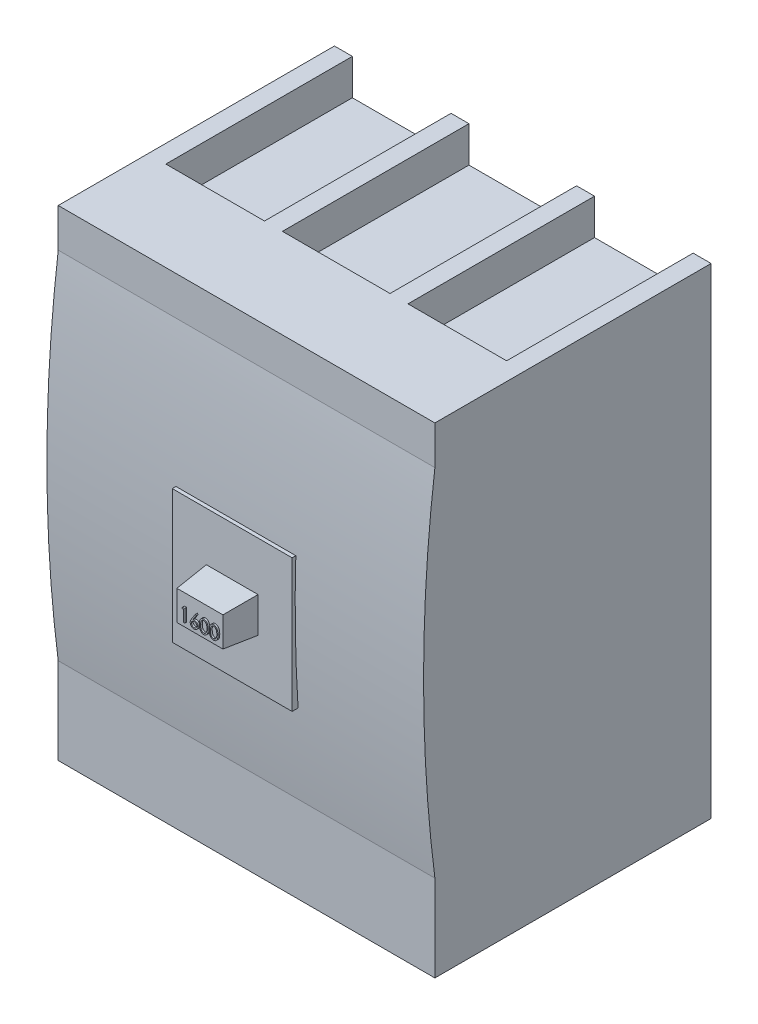
from build123d import *

# Parameters (mm, degrees)
CROQUIS1_W              = 210
CROQUIS1_H              = 268
SALIENTE_EXTRUIR1_DEPTH = 154
SALIENTE_EXTRUIR5_DEPTH = 210
CROQUIS9_W              = 66.83497729
CROQUIS9_H              = 74.198152754
SALIENTE_EXTRUIR6_DEPTH = 8
CROQUIS10_W             = 28.813391314
CROQUIS10_H             = 19.672193056
SALIENTE_EXTRUIR7_DEPTH = 18
SALIENTE_EXTRUIR7_TAPER = 5
CROQUIS11_W             = 55
CROQUIS11_H             = 104
CROQUIS11_W_2           = 60
CORTAR_EXTRUIR3_DEPTH   = 20
CROQUIS12_W             = 55
CROQUIS12_H             = 104
CORTAR_EXTRUIR4_DEPTH   = 20
SALIENTE_EXTRUIR8_DEPTH = 1


with BuildPart() as part:
    # Croquis1 → Saliente-Extruir1 (new body)
    with BuildSketch(Plane.XY):
        Rectangle(CROQUIS1_W, CROQUIS1_H)
    extrude(amount=SALIENTE_EXTRUIR1_DEPTH)

    # Croquis8 → Saliente-Extruir5 (add)
    with BuildSketch(Plane(origin=(105, 0, 0), x_dir=(0, 0, -1), z_dir=(1, 0, 0))):
        with BuildLine():
            Line((-154, -85.809314063), (-154, 112.430025356))
            ThreePointArc((-154, 112.430025356), (-160.313083336, 13.310355647), (-154, -85.809314063))
        make_face()
    extrude(amount=-SALIENTE_EXTRUIR5_DEPTH)

    # Croquis9 → Saliente-Extruir6 (add)
    with BuildSketch(Plane.XY.offset(154)):
        Rectangle(CROQUIS9_W, CROQUIS9_H)
    extrude(amount=SALIENTE_EXTRUIR6_DEPTH)

    # Croquis10 → Saliente-Extruir7 (add)
    with BuildSketch(Plane.XY.offset(162)):
        Rectangle(CROQUIS10_W, CROQUIS10_H)
    extrude(amount=SALIENTE_EXTRUIR7_DEPTH, taper=SALIENTE_EXTRUIR7_TAPER)

    # Croquis11 → Cortar-Extruir3 (cut)
    with BuildSketch(Plane.XZ.offset(134)):
        with Locations((67.5, 52)):
            Rectangle(CROQUIS11_W, CROQUIS11_H)
        with Locations((0, 52)):
            Rectangle(CROQUIS11_W_2, CROQUIS11_H)
        with Locations((-70, 52)):
            Rectangle(CROQUIS11_W_2, CROQUIS11_H)
    extrude(amount=-CORTAR_EXTRUIR3_DEPTH, mode=Mode.SUBTRACT)

    # Croquis12 → Cortar-Extruir4 (cut)
    with BuildSketch(Plane(origin=(0, 134, 0), x_dir=(1, 0, 0), z_dir=(0, 1, 0))):
        with Locations((-67.5, -52)):
            Rectangle(CROQUIS12_W, CROQUIS12_H)
        Polygon((-30, 0), (-30, -104), (28.731426376, -104), (30, -104), (30, 0), align=None)
        with Locations((67.5, -52)):
            Rectangle(CROQUIS12_W, CROQUIS12_H)
    extrude(amount=-CORTAR_EXTRUIR4_DEPTH, mode=Mode.SUBTRACT)

    # Croquis13 → Saliente-Extruir8 (add)
    with BuildSketch(Plane.XY.offset(180)):
        Polygon((-8.756675318, 1.705847668), (-7.435825708, 1.705847668), (-7.435825708, -5.437902332), (-8.076931478, -5.437902332), (-8.076931478, 0.97315536), (-9.175969939, 0.97315536), align=None)
        with BuildLine():
            Line((-1.482700708, 1.889020745), (-0.988992025, 1.501208996))
            Line((-0.988992025, 1.501208996), (-2.876533341, -1.385198005))
            add(Edge.make_bspline(
                [(-2.876533341, -1.385198005), (-2.750864007, -1.365167214), (-2.505731764, -1.326094893), (-2.257607082, -1.3196493), (-2.136685835, -1.316508101)],
                knots=[0, 0, 0, 0, 0.000381291, 0.000743751, 0.000743751, 0.000743751, 0.000743751], degree=3))
            add(Edge.make_bspline(
                [(-2.136685835, -1.316508101), (-2.064079829, -1.318459593), (-1.921157067, -1.322301048), (-1.71132104, -1.351863622), (-1.509685766, -1.398451306), (-1.317086975, -1.466362357), (-1.132833371, -1.553112698), (-0.955867587, -1.65708257), (-0.789516163, -1.783640593), (-0.631636881, -1.925015315), (-0.488298359, -2.08160016), (-0.361392589, -2.247746103), (-0.254793976, -2.423280044), (-0.168305776, -2.608113076), (-0.101144568, -2.801960282), (-0.052184071, -3.004573646), (-0.023242509, -3.216092881), (-0.019312445, -3.359943871), (-0.017316093, -3.433015763)],
                knots=[0, 0, 0, 0, 0.000217749, 0.000428632, 0.000634468, 0.00083768, 0.001039979, 0.001244663, 0.001452163, 0.001665964, 0.001879668, 0.002088031, 0.002292224, 0.002494522, 0.002699086, 0.002906646, 0.003118947, 0.003338125, 0.003338125, 0.003338125, 0.003338125], degree=3))
            add(Edge.make_bspline(
                [(-0.017316093, -3.433015763), (-0.020220752, -3.532986838), (-0.025936433, -3.729706253), (-0.082890074, -4.016225138), (-0.171390206, -4.289182754), (-0.297890768, -4.544221102), (-0.45501731, -4.780990633), (-0.646628183, -4.990783109), (-0.865928017, -5.177888203), (-1.11389125, -5.334349839), (-1.380746978, -5.462127137), (-1.661092216, -5.553904408), (-1.952204409, -5.610408347), (-2.149789529, -5.617492095), (-2.249737968, -5.621075409)],
                knots=[0, 0, 0, 0, 0.00029958, 0.000589502, 0.00087279, 0.001158228, 0.001440821, 0.001722485, 0.00200778, 0.002303132, 0.002599499, 0.002893197, 0.003185931, 0.003485597, 0.003485597, 0.003485597, 0.003485597], degree=3))
            add(Edge.make_bspline(
                [(-2.249737968, -5.621075409), (-2.345865698, -5.617956232), (-2.536277901, -5.611777688), (-2.816379836, -5.556738283), (-3.085521673, -5.467528964), (-3.341817749, -5.344627321), (-3.579236429, -5.189387749), (-3.791641826, -5.002502597), (-3.977974859, -4.787966671), (-4.133044487, -4.545813248), (-4.256036863, -4.285597138), (-4.348272728, -4.014262906), (-4.402149346, -3.732799194), (-4.409677954, -3.541997511), (-4.413469939, -3.44589512)],
                knots=[0, 0, 0, 0, 0.000288151, 0.000570777, 0.000852706, 0.001136893, 0.001421079, 0.001700957, 0.001982991, 0.002270776, 0.002560744, 0.002844484, 0.003128516, 0.003416756, 0.003416756, 0.003416756, 0.003416756], degree=3))
            add(Edge.make_bspline(
                [(-4.413469939, -3.44589512), (-4.411058526, -3.372325551), (-4.40613488, -3.222110548), (-4.371756317, -2.994604506), (-4.316515138, -2.761818101), (-4.25464976, -2.564335881), (-4.189283202, -2.402557453), (-4.134883465, -2.272125864), (-4.06717297, -2.137902817), (-3.994973372, -1.995285735), (-3.911785691, -1.847950111), (-3.821334285, -1.693433514), (-3.721118391, -1.534193351), (-3.65086438, -1.426130466), (-3.614949807, -1.370887608)],
                knots=[0, 0, 0, 0, 0.000220677, 0.000450581, 0.000688702, 0.000938068, 0.001070407, 0.001212087, 0.001361848, 0.001521214, 0.001691622, 0.001869313, 0.002058319, 0.002255994, 0.002255994, 0.002255994, 0.002255994], degree=3))
            Line((-3.614949807, -1.370887608), (-1.482700708, 1.889020745))
        make_face()
        with BuildLine():
            add(Edge.make_bspline(
                [(-2.271203563, -2.049200409), (-2.325623109, -2.050788452), (-2.431920291, -2.05389036), (-2.587873283, -2.07190333), (-2.735469794, -2.10582403), (-2.876665265, -2.149026025), (-3.008819951, -2.208427449), (-3.132894316, -2.280582996), (-3.249368163, -2.365534793), (-3.357021519, -2.462079331), (-3.454624868, -2.567782406), (-3.538678497, -2.680999663), (-3.611182253, -2.799002581), (-3.670132108, -2.922777117), (-3.716035959, -3.052275954), (-3.749240621, -3.186903493), (-3.767719974, -3.327562515), (-3.7707943, -3.422946891), (-3.77236417, -3.471653834)],
                knots=[0, 0, 0, 0, 0.000163295, 0.000318963, 0.000469991, 0.000617082, 0.000761219, 0.000903577, 0.001046981, 0.001192919, 0.001336737, 0.001477838, 0.001615277, 0.001751617, 0.00188831, 0.002026795, 0.002166847, 0.002312989, 0.002312989, 0.002312989, 0.002312989], degree=3))
            add(Edge.make_bspline(
                [(-3.77236417, -3.471653834), (-3.771085721, -3.519925133), (-3.768578874, -3.614577962), (-3.745816193, -3.754063109), (-3.711046373, -3.888293985), (-3.659324815, -4.016578587), (-3.597629577, -4.140872322), (-3.51617996, -4.256673092), (-3.425930342, -4.371014057), (-3.318051688, -4.475111703), (-3.202275253, -4.571974062), (-3.07858387, -4.656638223), (-2.949669881, -4.729068037), (-2.813792853, -4.785832474), (-2.67288058, -4.832418474), (-2.525759021, -4.8652011), (-2.372325853, -4.883735103), (-2.26839054, -4.886813433), (-2.215393016, -4.888383101)],
                knots=[0, 0, 0, 0, 0.000144712, 0.000283759, 0.000422953, 0.00055981, 0.000698051, 0.000838162, 0.000983657, 0.001134433, 0.001286878, 0.001436125, 0.001583459, 0.00172965, 0.001877179, 0.002028206, 0.002181033, 0.002340039, 0.002340039, 0.002340039, 0.002340039], degree=3))
            add(Edge.make_bspline(
                [(-2.215393016, -4.888383101), (-2.162395579, -4.88681331), (-2.058460437, -4.883734738), (-1.905026035, -4.865202485), (-1.757909038, -4.832413392), (-1.616980182, -4.785850898), (-1.481164368, -4.728999691), (-1.352363124, -4.657088826), (-1.229841497, -4.571453393), (-1.113989059, -4.475277234), (-1.006559432, -4.370421573), (-0.914145271, -4.257693765), (-0.835190029, -4.139936403), (-0.771030608, -4.01706821), (-0.719878723, -3.888216417), (-0.684932585, -3.754083889), (-0.662216911, -3.614572522), (-0.659703605, -3.519923295), (-0.658421862, -3.471653834)],
                knots=[0, 0, 0, 0, 0.000159006, 0.000311833, 0.00046286, 0.000610389, 0.00075658, 0.000903914, 0.001051984, 0.001204428, 0.001355204, 0.001501605, 0.001640916, 0.001779815, 0.001916673, 0.002055866, 0.002194913, 0.002339625, 0.002339625, 0.002339625, 0.002339625], degree=3))
            add(Edge.make_bspline(
                [(-0.658421862, -3.471653834), (-0.65954505, -3.422883349), (-0.661749501, -3.327162748), (-0.686683125, -3.186966413), (-0.72126372, -3.051591929), (-0.773480513, -2.921890108), (-0.841318675, -2.798372778), (-0.9239482, -2.680415993), (-1.019536821, -2.567115409), (-1.129953764, -2.461872034), (-1.250152938, -2.36564148), (-1.37795582, -2.280692993), (-1.511662273, -2.209000407), (-1.651136731, -2.149182517), (-1.797977293, -2.10601493), (-1.949813289, -2.072024471), (-2.10858669, -2.05393646), (-2.216307517, -2.050799201), (-2.271203563, -2.049200409)],
                knots=[0, 0, 0, 0, 0.000146141, 0.000286828, 0.000426022, 0.000564737, 0.000704986, 0.000847897, 0.000996132, 0.001148959, 0.001304732, 0.001457538, 0.00160864, 0.001759342, 0.0019119, 0.00206712, 0.00222563, 0.002390355, 0.002390355, 0.002390355, 0.002390355], degree=3))
        make_face(mode=Mode.SUBTRACT)
        with BuildLine():
            add(Edge.make_bspline(
                [(0.715376215, -1.868889411), (0.716045723, -1.754390636), (0.717346253, -1.531975115), (0.731814226, -1.207884318), (0.755848541, -0.903845728), (0.788786072, -0.619844792), (0.828868592, -0.35580819), (0.882376273, -0.112441534), (0.943226333, 0.111381556), (1.013750342, 0.316390951), (1.093327205, 0.505348656), (1.179938562, 0.681748665), (1.277021705, 0.845324073), (1.379028154, 0.99868567), (1.490087079, 1.139323033), (1.607038003, 1.269222253), (1.734445511, 1.38538116), (1.867978544, 1.491203166), (2.008846077, 1.583968784), (2.153032805, 1.665678463), (2.301531173, 1.735482835), (2.454746614, 1.790368136), (2.611302013, 1.83570206), (2.771744651, 1.866703787), (2.936339435, 1.88621012), (3.047437881, 1.888074981), (3.103781413, 1.889020745)],
                knots=[0, 0, 0, 0, 0.000343476, 0.000667208, 0.000972988, 0.00125824, 0.001524801, 0.001773773, 0.002005341, 0.002220307, 0.002423625, 0.0026201, 0.002809328, 0.002993888, 0.00317224, 0.003346475, 0.003517632, 0.003688831, 0.003857117, 0.004023081, 0.004185697, 0.004348673, 0.004510842, 0.004674181, 0.004838377, 0.005007336, 0.005007336, 0.005007336, 0.005007336], degree=3))
            add(Edge.make_bspline(
                [(3.103781413, 1.889020745), (3.160595613, 1.888025079), (3.273581181, 1.886045014), (3.440623233, 1.867014181), (3.603806244, 1.835436514), (3.762434516, 1.790694239), (3.917811051, 1.73518592), (4.06872054, 1.665611679), (4.216100351, 1.584624277), (4.35760842, 1.489461613), (4.494798251, 1.383362074), (4.624300076, 1.26342327), (4.746125681, 1.130856254), (4.861804028, 0.987079378), (4.96805322, 0.829334999), (5.069236136, 0.660366718), (5.159802631, 0.477219614), (5.247027155, 0.28294948), (5.32231613, 0.072180977), (5.390214913, -0.153897811), (5.445076808, -0.397957268), (5.490774912, -0.65871689), (5.526177083, -0.937134307), (5.551961208, -1.232612697), (5.565581451, -1.545346459), (5.568146468, -1.759164711), (5.569462753, -1.868889411)],
                knots=[0, 0, 0, 0, 0.00017039, 0.000338852, 0.000503596, 0.000668519, 0.00083284, 0.000998055, 0.001166517, 0.001336787, 0.001509113, 0.001686337, 0.001865583, 0.002048845, 0.002239367, 0.002435706, 0.002639221, 0.002851941, 0.003074214, 0.003310109, 0.003559706, 0.00382415, 0.004104068, 0.004401411, 0.004713705, 0.005042894, 0.005042894, 0.005042894, 0.005042894], degree=3))
            add(Edge.make_bspline(
                [(5.569462753, -1.868889411), (5.568132822, -1.978135531), (5.565541507, -2.190997139), (5.552113897, -2.502323754), (5.525664405, -2.796234046), (5.492578661, -3.073432901), (5.446754642, -3.332766577), (5.390410525, -3.575132478), (5.327851027, -3.801577252), (5.25062751, -4.010245805), (5.166105292, -4.204049054), (5.074144419, -4.385025037), (4.975622256, -4.554773381), (4.868284871, -4.711935364), (4.753875851, -4.857624302), (4.629946507, -4.989268557), (4.499990295, -5.110040125), (4.362396739, -5.217505857), (4.218681733, -5.311568235), (4.071808117, -5.395688648), (3.91916989, -5.463518952), (3.764226132, -5.521761009), (3.604760556, -5.566257288), (3.44097194, -5.597024104), (3.273693409, -5.618602002), (3.160614857, -5.620248085), (3.103781413, -5.621075409)],
                knots=[0, 0, 0, 0, 0.000327758, 0.000638623, 0.000934541, 0.001212859, 0.001475894, 0.001724095, 0.001959191, 0.002180119, 0.002390953, 0.002593191, 0.002788805, 0.002979326, 0.003163709, 0.003343929, 0.003521152, 0.003695487, 0.003866949, 0.004036109, 0.004202627, 0.004367439, 0.004532362, 0.004698511, 0.004867137, 0.005037527, 0.005037527, 0.005037527, 0.005037527], degree=3))
            add(Edge.make_bspline(
                [(3.103781413, -5.621075409), (3.047439445, -5.620123544), (2.93634408, -5.618246652), (2.771726719, -5.598828447), (2.61194666, -5.567609232), (2.456215453, -5.523896414), (2.30373412, -5.47039006), (2.156580449, -5.400679952), (2.013118266, -5.320396308), (1.873730322, -5.228965653), (1.741035858, -5.124214432), (1.614288169, -5.008354464), (1.496671389, -4.878494537), (1.387200369, -4.736685134), (1.283158614, -4.584230891), (1.187454054, -4.419050301), (1.098931043, -4.24179833), (1.018015846, -4.051329809), (0.946274914, -3.844865375), (0.882904324, -3.620043034), (0.832869177, -3.374878441), (0.790041467, -3.111340672), (0.755497592, -2.828297275), (0.731914389, -2.525594589), (0.717338454, -2.203421243), (0.71604223, -1.9824349), (0.715376215, -1.868889411)],
                knots=[0, 0, 0, 0, 0.00016896, 0.000333155, 0.000496495, 0.000656899, 0.000818042, 0.000980659, 0.001144673, 0.001310976, 0.001480166, 0.001651323, 0.001825558, 0.002005038, 0.002188412, 0.002378875, 0.002577269, 0.002782462, 0.002999249, 0.003232579, 0.003482651, 0.003749439, 0.004033438, 0.004337792, 0.004660094, 0.005000709, 0.005000709, 0.005000709, 0.005000709], degree=3))
        make_face()
        with BuildLine():
            add(Edge.make_bspline(
                [(1.356481984, -1.866027332), (1.356725784, -1.961444765), (1.357198952, -2.146631268), (1.36956009, -2.415732781), (1.386399403, -2.666724005), (1.40811905, -2.899923634), (1.440373997, -3.11454232), (1.476514816, -3.312056156), (1.520496006, -3.491419874), (1.572533158, -3.65386428), (1.631804029, -3.802146218), (1.696517962, -3.940125127), (1.76603833, -4.069430954), (1.843842239, -4.18890223), (1.928577448, -4.298928561), (2.018330011, -4.40145736), (2.11644959, -4.492891199), (2.252188478, -4.602551547), (2.431387354, -4.715870065), (2.657171604, -4.814547888), (2.889177032, -4.876560651), (3.046648244, -4.884446853), (3.125247008, -4.888383101)],
                knots=[0, 0, 0, 0, 0.000286222, 0.000555501, 0.000807949, 0.001040905, 0.001257858, 0.001458816, 0.001643114, 0.001811467, 0.001970112, 0.002121836, 0.002268481, 0.002410183, 0.002549001, 0.002684837, 0.002818469, 0.002950776, 0.003208045, 0.003451574, 0.003687939, 0.003923483, 0.003923483, 0.003923483, 0.003923483], degree=3))
            add(Edge.make_bspline(
                [(3.125247008, -4.888383101), (3.204354184, -4.885121916), (3.36240521, -4.87860628), (3.593319367, -4.815743857), (3.817490793, -4.720896208), (3.993169771, -4.608744424), (4.12682432, -4.501938566), (4.222585248, -4.410876882), (4.310477964, -4.308913389), (4.393839556, -4.198901076), (4.470296206, -4.078738131), (4.539821503, -3.949002374), (4.603264835, -3.809333534), (4.639410263, -3.711832085), (4.657890487, -3.66198211)],
                knots=[0, 0, 0, 0, 0.000236853, 0.000473218, 0.000712984, 0.000965095, 0.00109539, 0.00122596, 0.00136085, 0.001498803, 0.00163973, 0.001787633, 0.001940057, 0.002099514, 0.002099514, 0.002099514, 0.002099514], degree=3))
            add(Edge.make_bspline(
                [(4.657890487, -3.66198211), (4.679427399, -3.598239981), (4.723156566, -3.468816123), (4.77951417, -3.268048883), (4.823898083, -3.05740467), (4.86382831, -2.838142333), (4.891082851, -2.608644872), (4.913019905, -2.369622378), (4.92594129, -2.120894633), (4.927543023, -1.951904142), (4.928356984, -1.866027332)],
                knots=[0, 0, 0, 0, 0.000201832, 0.000409806, 0.000625096, 0.000847428, 0.001078176, 0.001318122, 0.001567456, 0.001825079, 0.001825079, 0.001825079, 0.001825079], degree=3))
            add(Edge.make_bspline(
                [(4.928356984, -1.866027332), (4.927234008, -1.780164412), (4.925037228, -1.612198184), (4.916640285, -1.366211969), (4.894956811, -1.132575093), (4.870873967, -0.910281039), (4.835364996, -0.700560332), (4.797078972, -0.501657298), (4.745641498, -0.316036088), (4.690696314, -0.140790549), (4.627810096, 0.022088287), (4.55858566, 0.173359819), (4.484654463, 0.313754355), (4.40435414, 0.442886702), (4.318637951, 0.561335267), (4.225243525, 0.666725163), (4.127875493, 0.76232276), (3.991496844, 0.871443682), (3.81295557, 0.982705947), (3.590793829, 1.085097846), (3.359600353, 1.143897629), (3.203308464, 1.152187822), (3.125247008, 1.156328437)],
                knots=[0, 0, 0, 0, 0.000257623, 0.000503965, 0.000738084, 0.000961386, 0.001174534, 0.001376041, 0.001568701, 0.001751991, 0.001926859, 0.002092075, 0.002250836, 0.002402526, 0.00254793, 0.002688879, 0.002824488, 0.002956795, 0.00321209, 0.00345358, 0.003688205, 0.003922324, 0.003922324, 0.003922324, 0.003922324], degree=3))
            add(Edge.make_bspline(
                [(3.125247008, 1.156328437), (3.046235924, 1.15218211), (2.888069818, 1.143881901), (2.654473368, 1.08531692), (2.43055895, 0.983236885), (2.252489807, 0.871075167), (2.116016043, 0.764248935), (2.019916903, 0.67161194), (1.929811412, 0.570280389), (1.846805731, 0.459242195), (1.769062783, 0.339910204), (1.697664038, 0.211345636), (1.633334917, 0.072896977), (1.573971301, -0.075318355), (1.521775414, -0.237748747), (1.478721128, -0.416891532), (1.438946661, -0.613777143), (1.410789532, -0.82955821), (1.38575833, -1.062816248), (1.369671936, -1.31443406), (1.357157602, -1.583986894), (1.3567117, -1.770130891), (1.356481984, -1.866027332)],
                knots=[0, 0, 0, 0, 0.00023697, 0.000474372, 0.000717168, 0.000972463, 0.001103878, 0.001236471, 0.001372307, 0.001510259, 0.001651961, 0.001799296, 0.00195102, 0.002109665, 0.002278018, 0.002462316, 0.00266214, 0.002880307, 0.003114831, 0.003365851, 0.00363656, 0.003924213, 0.003924213, 0.003924213, 0.003924213], degree=3))
        make_face(mode=Mode.SUBTRACT)
        with BuildLine():
            add(Edge.make_bspline(
                [(6.210568522, -1.868889411), (6.211238031, -1.754390636), (6.212538561, -1.531975115), (6.227006534, -1.207884318), (6.251040849, -0.903845728), (6.28397838, -0.619844792), (6.3240609, -0.35580819), (6.377568581, -0.112441534), (6.43841864, 0.111381556), (6.50894265, 0.316390951), (6.588519512, 0.505348656), (6.67513087, 0.681748665), (6.772214012, 0.845324073), (6.874220461, 0.99868567), (6.985279386, 1.139323033), (7.10223031, 1.269222253), (7.229637819, 1.38538116), (7.363170851, 1.491203166), (7.504038385, 1.583968784), (7.648225113, 1.665678463), (7.79672348, 1.735482835), (7.949938922, 1.790368136), (8.106494321, 1.83570206), (8.266936959, 1.866703787), (8.431531743, 1.88621012), (8.542630189, 1.888074981), (8.598973721, 1.889020745)],
                knots=[0, 0, 0, 0, 0.000343476, 0.000667208, 0.000972988, 0.00125824, 0.001524801, 0.001773773, 0.002005341, 0.002220307, 0.002423625, 0.0026201, 0.002809328, 0.002993888, 0.00317224, 0.003346475, 0.003517632, 0.003688831, 0.003857117, 0.004023081, 0.004185697, 0.004348673, 0.004510842, 0.004674181, 0.004838377, 0.005007336, 0.005007336, 0.005007336, 0.005007336], degree=3))
            add(Edge.make_bspline(
                [(8.598973721, 1.889020745), (8.65578792, 1.888025079), (8.768773489, 1.886045014), (8.93581554, 1.867014181), (9.098998551, 1.835436514), (9.257626824, 1.790694239), (9.413003359, 1.73518592), (9.563912848, 1.665611679), (9.711292659, 1.584624277), (9.852800728, 1.489461613), (9.989990559, 1.383362074), (10.119492383, 1.26342327), (10.241317989, 1.130856254), (10.356996336, 0.987079378), (10.463245528, 0.829334999), (10.564428444, 0.660366718), (10.654994939, 0.477219614), (10.742219463, 0.28294948), (10.817508438, 0.072180977), (10.885407221, -0.153897811), (10.940269115, -0.397957268), (10.985967219, -0.65871689), (11.021369391, -0.937134307), (11.047153516, -1.232612697), (11.060773759, -1.545346459), (11.063338776, -1.759164711), (11.064655061, -1.868889411)],
                knots=[0, 0, 0, 0, 0.00017039, 0.000338852, 0.000503596, 0.000668519, 0.00083284, 0.000998055, 0.001166517, 0.001336787, 0.001509113, 0.001686337, 0.001865583, 0.002048845, 0.002239367, 0.002435706, 0.002639221, 0.002851941, 0.003074214, 0.003310109, 0.003559706, 0.00382415, 0.004104068, 0.004401411, 0.004713705, 0.005042894, 0.005042894, 0.005042894, 0.005042894], degree=3))
            add(Edge.make_bspline(
                [(11.064655061, -1.868889411), (11.06332513, -1.978135531), (11.060733815, -2.190997139), (11.047306204, -2.502323754), (11.020856712, -2.796234046), (10.987770968, -3.073432901), (10.941946949, -3.332766577), (10.885602833, -3.575132478), (10.823043335, -3.801577252), (10.745819818, -4.010245805), (10.6612976, -4.204049054), (10.569336726, -4.385025037), (10.470814563, -4.554773381), (10.363477179, -4.711935364), (10.249068158, -4.857624302), (10.125138815, -4.989268557), (9.995182602, -5.110040125), (9.857589047, -5.217505857), (9.713874041, -5.311568235), (9.567000425, -5.395688648), (9.414362198, -5.463518952), (9.259418439, -5.521761009), (9.099952863, -5.566257288), (8.936164248, -5.597024104), (8.768885717, -5.618602002), (8.655807165, -5.620248085), (8.598973721, -5.621075409)],
                knots=[0, 0, 0, 0, 0.000327758, 0.000638623, 0.000934541, 0.001212859, 0.001475894, 0.001724095, 0.001959191, 0.002180119, 0.002390953, 0.002593191, 0.002788805, 0.002979326, 0.003163709, 0.003343929, 0.003521152, 0.003695487, 0.003866949, 0.004036109, 0.004202627, 0.004367439, 0.004532362, 0.004698511, 0.004867137, 0.005037527, 0.005037527, 0.005037527, 0.005037527], degree=3))
            add(Edge.make_bspline(
                [(8.598973721, -5.621075409), (8.542631752, -5.620123544), (8.431536388, -5.618246652), (8.266919027, -5.598828447), (8.107138968, -5.567609232), (7.951407761, -5.523896414), (7.798926428, -5.47039006), (7.651772757, -5.400679952), (7.508310574, -5.320396308), (7.36892263, -5.228965653), (7.236228166, -5.124214432), (7.109480477, -5.008354464), (6.991863697, -4.878494537), (6.882392676, -4.736685134), (6.778350921, -4.584230891), (6.682646361, -4.419050301), (6.59412335, -4.24179833), (6.513208154, -4.051329809), (6.441467221, -3.844865375), (6.378096631, -3.620043034), (6.328061485, -3.374878441), (6.285233774, -3.111340672), (6.2506899, -2.828297275), (6.227106696, -2.525594589), (6.212530762, -2.203421243), (6.211234538, -1.9824349), (6.210568522, -1.868889411)],
                knots=[0, 0, 0, 0, 0.00016896, 0.000333155, 0.000496495, 0.000656899, 0.000818042, 0.000980659, 0.001144673, 0.001310976, 0.001480166, 0.001651323, 0.001825558, 0.002005038, 0.002188412, 0.002378875, 0.002577269, 0.002782462, 0.002999249, 0.003232579, 0.003482651, 0.003749439, 0.004033438, 0.004337792, 0.004660094, 0.005000709, 0.005000709, 0.005000709, 0.005000709], degree=3))
        make_face()
        with BuildLine():
            add(Edge.make_bspline(
                [(6.851674292, -1.866027332), (6.851918092, -1.961444765), (6.852391259, -2.146631268), (6.864752397, -2.415732781), (6.88159171, -2.666724005), (6.903311358, -2.899923634), (6.935566305, -3.11454232), (6.971707123, -3.312056156), (7.015688313, -3.491419874), (7.067725466, -3.65386428), (7.126996337, -3.802146218), (7.191710269, -3.940125127), (7.261230638, -4.069430954), (7.339034547, -4.18890223), (7.423769756, -4.298928561), (7.513522319, -4.40145736), (7.611641897, -4.492891199), (7.747380786, -4.602551547), (7.926579662, -4.715870065), (8.152363912, -4.814547888), (8.38436934, -4.876560651), (8.541840552, -4.884446853), (8.620439316, -4.888383101)],
                knots=[0, 0, 0, 0, 0.000286222, 0.000555501, 0.000807949, 0.001040905, 0.001257858, 0.001458816, 0.001643114, 0.001811467, 0.001970112, 0.002121836, 0.002268481, 0.002410183, 0.002549001, 0.002684837, 0.002818469, 0.002950776, 0.003208045, 0.003451574, 0.003687939, 0.003923483, 0.003923483, 0.003923483, 0.003923483], degree=3))
            add(Edge.make_bspline(
                [(8.620439316, -4.888383101), (8.699546492, -4.885121916), (8.857597518, -4.87860628), (9.088511674, -4.815743857), (9.312683101, -4.720896208), (9.488362079, -4.608744424), (9.622016627, -4.501938566), (9.717777555, -4.410876882), (9.805670272, -4.308913389), (9.889031864, -4.198901076), (9.965488513, -4.078738131), (10.03501381, -3.949002374), (10.098457143, -3.809333534), (10.134602571, -3.711832085), (10.153082795, -3.66198211)],
                knots=[0, 0, 0, 0, 0.000236853, 0.000473218, 0.000712984, 0.000965095, 0.00109539, 0.00122596, 0.00136085, 0.001498803, 0.00163973, 0.001787633, 0.001940057, 0.002099514, 0.002099514, 0.002099514, 0.002099514], degree=3))
            add(Edge.make_bspline(
                [(10.153082795, -3.66198211), (10.174619707, -3.598239981), (10.218348874, -3.468816123), (10.274706478, -3.268048883), (10.319090391, -3.05740467), (10.359020618, -2.838142333), (10.386275158, -2.608644872), (10.408212213, -2.369622378), (10.421133597, -2.120894633), (10.42273533, -1.951904142), (10.423549292, -1.866027332)],
                knots=[0, 0, 0, 0, 0.000201832, 0.000409806, 0.000625096, 0.000847428, 0.001078176, 0.001318122, 0.001567456, 0.001825079, 0.001825079, 0.001825079, 0.001825079], degree=3))
            add(Edge.make_bspline(
                [(10.423549292, -1.866027332), (10.422426316, -1.780164412), (10.420229536, -1.612198184), (10.411832593, -1.366211969), (10.390149119, -1.132575093), (10.366066274, -0.910281039), (10.330557303, -0.700560332), (10.29227128, -0.501657298), (10.240833805, -0.316036088), (10.185888622, -0.140790549), (10.123002404, 0.022088287), (10.053777968, 0.173359819), (9.979846771, 0.313754355), (9.899546448, 0.442886702), (9.813830259, 0.561335267), (9.720435833, 0.666725163), (9.6230678, 0.76232276), (9.486689151, 0.871443682), (9.308147878, 0.982705947), (9.085986137, 1.085097846), (8.854792661, 1.143897629), (8.698500772, 1.152187822), (8.620439316, 1.156328437)],
                knots=[0, 0, 0, 0, 0.000257623, 0.000503965, 0.000738084, 0.000961386, 0.001174534, 0.001376041, 0.001568701, 0.001751991, 0.001926859, 0.002092075, 0.002250836, 0.002402526, 0.00254793, 0.002688879, 0.002824488, 0.002956795, 0.00321209, 0.00345358, 0.003688205, 0.003922324, 0.003922324, 0.003922324, 0.003922324], degree=3))
            add(Edge.make_bspline(
                [(8.620439316, 1.156328437), (8.541428232, 1.15218211), (8.383262126, 1.143881901), (8.149665675, 1.08531692), (7.925751258, 0.983236885), (7.747682115, 0.871075167), (7.61120835, 0.764248935), (7.51510921, 0.67161194), (7.425003719, 0.570280389), (7.341998039, 0.459242195), (7.264255091, 0.339910204), (7.192856346, 0.211345636), (7.128527225, 0.072896977), (7.069163609, -0.075318355), (7.016967722, -0.237748747), (6.973913436, -0.416891532), (6.934138969, -0.613777143), (6.905981839, -0.82955821), (6.880950638, -1.062816248), (6.864864244, -1.31443406), (6.852349909, -1.583986894), (6.851904008, -1.770130891), (6.851674292, -1.866027332)],
                knots=[0, 0, 0, 0, 0.00023697, 0.000474372, 0.000717168, 0.000972463, 0.001103878, 0.001236471, 0.001372307, 0.001510259, 0.001651961, 0.001799296, 0.00195102, 0.002109665, 0.002278018, 0.002462316, 0.00266214, 0.002880307, 0.003114831, 0.003365851, 0.00363656, 0.003924213, 0.003924213, 0.003924213, 0.003924213], degree=3))
        make_face(mode=Mode.SUBTRACT)
    extrude(amount=SALIENTE_EXTRUIR8_DEPTH)


solid = part.part
